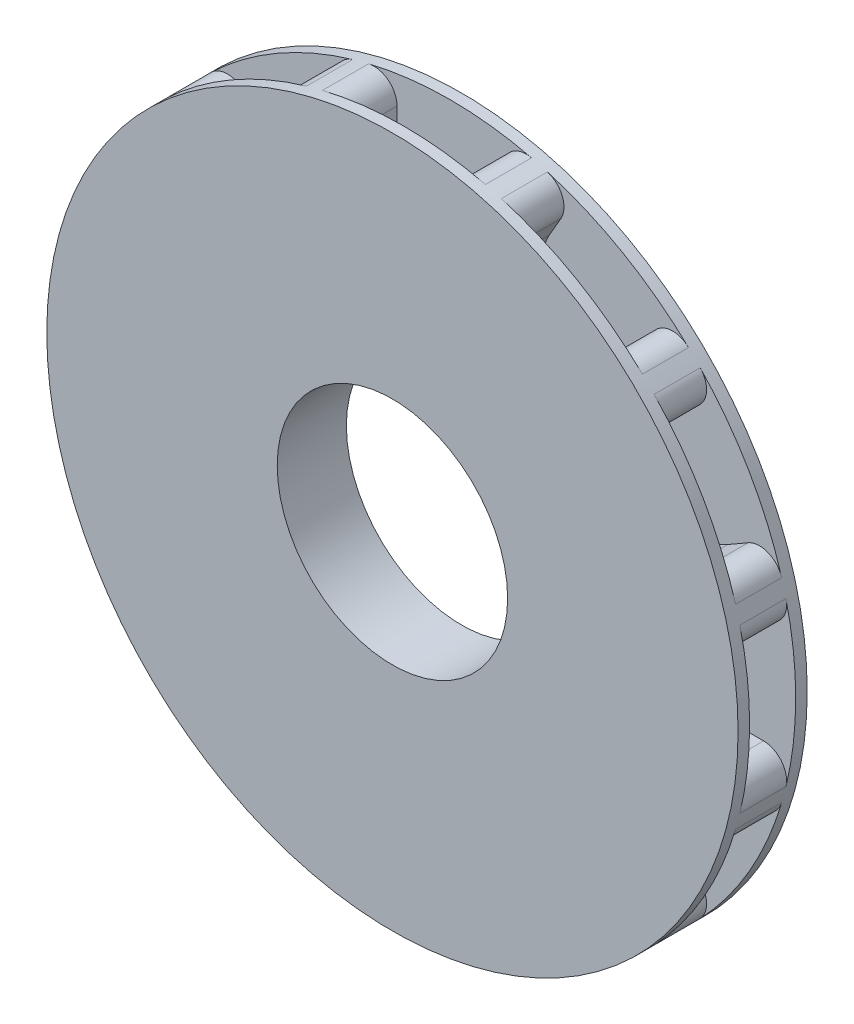
from build123d import *

# Parameters (mm, degrees)
SKETCH1_R               = 7.5
SKETCH1_R_2             = 2.5
BOSS_EXTRUDE1_DEPTH     = 1.5
CUT_EXTRUDE1_DEPTH      = 0.5
CUT_EXTRUDE1_DEPTH_BACK = 0.5
FILLET1_R               = 0.5


with BuildPart() as part:
    # Sketch1 → Boss-Extrude1 (new body)
    with BuildSketch(Plane.XY):
        Circle(SKETCH1_R)
        Circle(SKETCH1_R_2, mode=Mode.SUBTRACT)
    extrude(amount=BOSS_EXTRUDE1_DEPTH)

    # Sketch2 → Cut-Extrude1 (cut, two sides)
    with BuildSketch(Plane.XY.offset(0.75)) as cut_extrude1_sk:
        with BuildLine():
            Line((1.150031334, 6.294964197), (1.150031334, 7.644964197))
            Line((1.150031334, 7.644964197), (-1.150031334, 7.644964197))
            Line((-1.150031334, 7.644964197), (-1.150031334, 6.294964197))
            ThreePointArc((-1.150031334, 6.294964197), (0, 5.144932863), (1.150031334, 6.294964197))
        make_face()
        with BuildLine():
            Line((2.151525748, 6.026614578), (2.826525748, 7.195748873))
            Line((2.826525748, 7.195748873), (4.818438449, 6.045717539))
            Line((4.818438449, 6.045717539), (4.143438449, 4.876583244))
            ThreePointArc((4.143438449, 4.876583244), (2.572466432, 4.45564256), (2.151525748, 6.026614578))
        make_face()
        with BuildLine():
            Line((4.876583244, 4.143438449), (6.045717539, 4.818438449))
            Line((6.045717539, 4.818438449), (7.195748873, 2.826525748))
            Line((7.195748873, 2.826525748), (6.026614578, 2.151525748))
            ThreePointArc((6.026614578, 2.151525748), (4.45564256, 2.572466432), (4.876583244, 4.143438449))
        make_face()
        with BuildLine():
            Line((6.294964197, 1.150031334), (7.644964197, 1.150031334))
            Line((7.644964197, 1.150031334), (7.644964197, -1.150031334))
            Line((7.644964197, -1.150031334), (6.294964197, -1.150031334))
            ThreePointArc((6.294964197, -1.150031334), (5.144932863, 0), (6.294964197, 1.150031334))
        make_face()
        with BuildLine():
            Line((6.026614578, -2.151525748), (7.195748873, -2.826525748))
            Line((7.195748873, -2.826525748), (6.045717539, -4.818438449))
            Line((6.045717539, -4.818438449), (4.876583244, -4.143438449))
            ThreePointArc((4.876583244, -4.143438449), (4.45564256, -2.572466432), (6.026614578, -2.151525748))
        make_face()
        with BuildLine():
            Line((4.143438449, -4.876583244), (4.818438449, -6.045717539))
            Line((4.818438449, -6.045717539), (2.826525748, -7.195748873))
            Line((2.826525748, -7.195748873), (2.151525748, -6.026614578))
            ThreePointArc((2.151525748, -6.026614578), (2.572466432, -4.45564256), (4.143438449, -4.876583244))
        make_face()
        with BuildLine():
            Line((1.150031334, -6.294964197), (1.150031334, -7.644964197))
            Line((1.150031334, -7.644964197), (-1.150031334, -7.644964197))
            Line((-1.150031334, -7.644964197), (-1.150031334, -6.294964197))
            ThreePointArc((-1.150031334, -6.294964197), (0, -5.144932863), (1.150031334, -6.294964197))
        make_face()
        with BuildLine():
            Line((-2.151525748, -6.026614578), (-2.826525748, -7.195748873))
            Line((-2.826525748, -7.195748873), (-4.818438449, -6.045717539))
            Line((-4.818438449, -6.045717539), (-4.143438449, -4.876583244))
            ThreePointArc((-4.143438449, -4.876583244), (-2.572466432, -4.45564256), (-2.151525748, -6.026614578))
        make_face()
        with BuildLine():
            Line((-4.876583244, -4.143438449), (-6.045717539, -4.818438449))
            Line((-6.045717539, -4.818438449), (-7.195748873, -2.826525748))
            Line((-7.195748873, -2.826525748), (-6.026614578, -2.151525748))
            ThreePointArc((-6.026614578, -2.151525748), (-4.45564256, -2.572466432), (-4.876583244, -4.143438449))
        make_face()
        with BuildLine():
            Line((-6.294964197, -1.150031334), (-7.644964197, -1.150031334))
            Line((-7.644964197, -1.150031334), (-7.644964197, 1.150031334))
            Line((-7.644964197, 1.150031334), (-6.294964197, 1.150031334))
            ThreePointArc((-6.294964197, 1.150031334), (-5.144932863, 0), (-6.294964197, -1.150031334))
        make_face()
        with BuildLine():
            Line((-6.026614578, 2.151525748), (-7.195748873, 2.826525748))
            Line((-7.195748873, 2.826525748), (-6.045717539, 4.818438449))
            Line((-6.045717539, 4.818438449), (-4.876583244, 4.143438449))
            ThreePointArc((-4.876583244, 4.143438449), (-4.45564256, 2.572466432), (-6.026614578, 2.151525748))
        make_face()
        with BuildLine():
            Line((-4.143438449, 4.876583244), (-4.818438449, 6.045717539))
            Line((-4.818438449, 6.045717539), (-2.826525748, 7.195748873))
            Line((-2.826525748, 7.195748873), (-2.151525748, 6.026614578))
            ThreePointArc((-2.151525748, 6.026614578), (-2.572466432, 4.45564256), (-4.143438449, 4.876583244))
        make_face()
    extrude(amount=CUT_EXTRUDE1_DEPTH, mode=Mode.SUBTRACT)
    extrude(cut_extrude1_sk.sketch, amount=-CUT_EXTRUDE1_DEPTH_BACK, mode=Mode.SUBTRACT)

    # Fillet1
    fillet1_edges = [part.edges().sort_by_distance(p)[0] for p in [
        (-1.150031334, 7.411304064, 0.75),
        (1.150031334, 7.411304064, 0.75),
        (-7.411304064, -1.150031334, 0.75),
        (-7.411304064, 1.150031334, 0.75),
        (-6.993393262, 2.709695681, 0.75),
        (-5.843361928, 4.701608383, 0.75),
        (-4.701608383, 5.843361928, 0.75),
        (-2.709695681, 6.993393262, 0.75),
        (5.843361928, 4.701608383, 0.75),
        (6.993393262, 2.709695681, 0.75),
        (2.709695681, 6.993393262, 0.75),
        (4.701608383, 5.843361928, 0.75),
        (7.411304064, 1.150031334, 0.75),
        (7.411304064, -1.150031334, 0.75),
        (6.993393262, -2.709695681, 0.75),
        (5.843361928, -4.701608383, 0.75),
        (4.701608383, -5.843361928, 0.75),
        (2.709695681, -6.993393262, 0.75),
        (1.150031334, -7.411304064, 0.75),
        (-1.150031334, -7.411304064, 0.75),
        (-5.843361928, -4.701608383, 0.75),
        (-6.993393262, -2.709695681, 0.75),
        (-2.709695681, -6.993393262, 0.75),
        (-4.701608383, -5.843361928, 0.75),
    ]]
    fillet(fillet1_edges, radius=FILLET1_R)


solid = part.part
